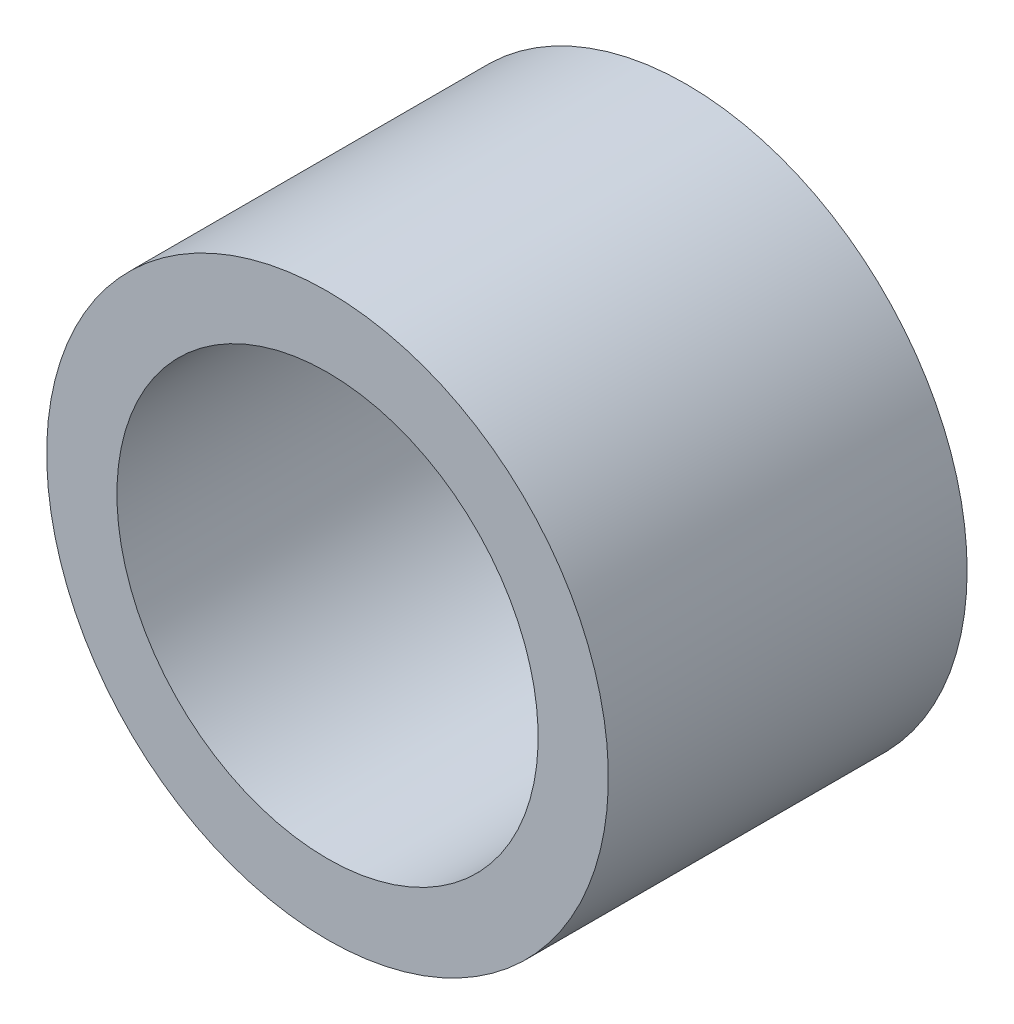
from build123d import *

# Parameters (mm, degrees)
SKETCH1_R           = 12.7
SKETCH1_R_2         = 9.525
BOSS_EXTRUDE1_DEPTH = 16.22425


with BuildPart() as part:
    # Sketch1 → Boss-Extrude1 (new body)
    with BuildSketch(Plane.XY):
        Circle(SKETCH1_R)
        Circle(SKETCH1_R_2, mode=Mode.SUBTRACT)
    extrude(amount=BOSS_EXTRUDE1_DEPTH)


solid = part.part
